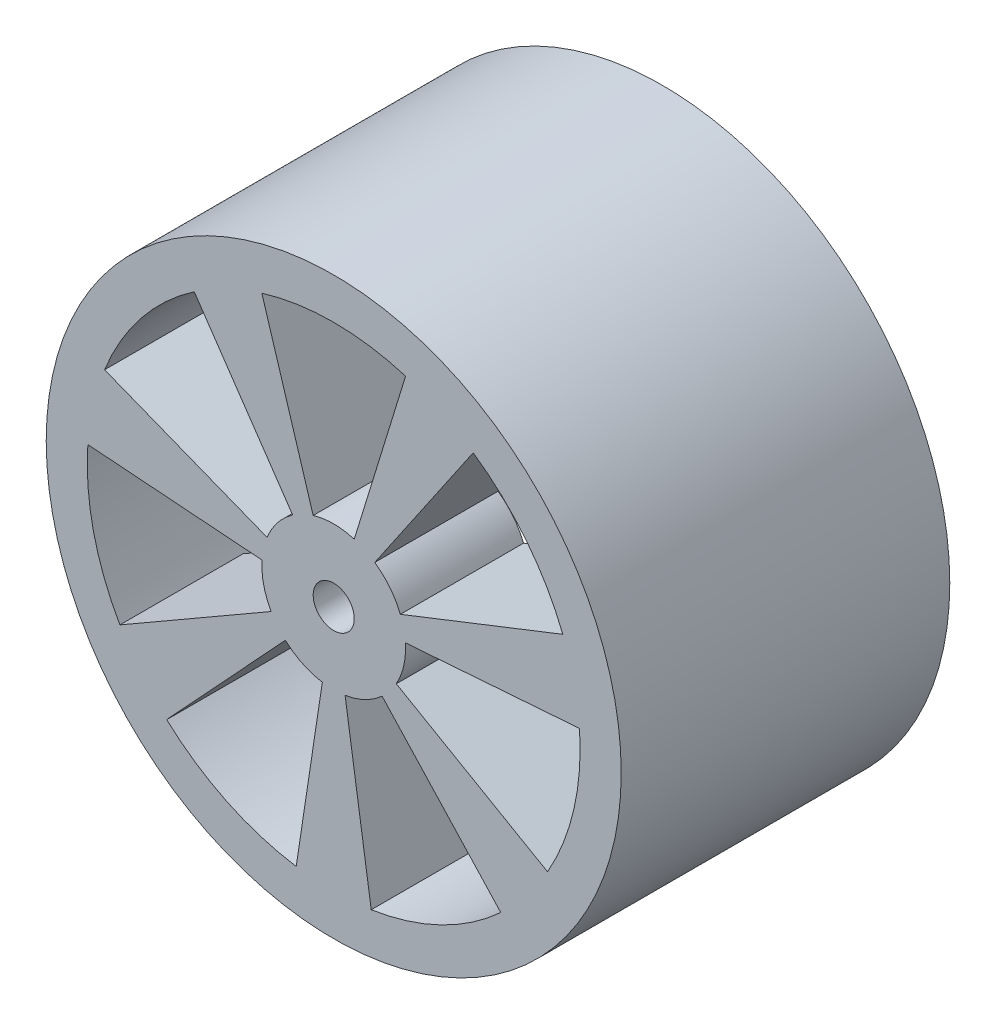
from build123d import *
from build123d.topology import SkipClean

# Parameters (mm, degrees)
SKETCH1_R           = 28
SKETCH1_R_2         = 2
BOSS_EXTRUDE1_DEPTH = 32
SKETCH2_R           = 24
CUT_EXTRUDE1_DEPTH  = 20
CUT_EXTRUDE2_DEPTH  = 4
CUT_EXTRUDE4_DEPTH  = 51.911688245


with BuildPart() as part:
    # Sketch1 → Boss-Extrude1 (new body)
    with BuildSketch(Plane.XY):
        Circle(SKETCH1_R)
        Circle(SKETCH1_R_2, mode=Mode.SUBTRACT)
    extrude(amount=BOSS_EXTRUDE1_DEPTH)

    # Sketch2 → Cut-Extrude1 (cut)
    with BuildSketch(Plane(origin=(0, 0, 0), x_dir=(-1, 0, 0), z_dir=(0, 0, -1))):
        Circle(SKETCH2_R)
    extrude(amount=-CUT_EXTRUDE1_DEPTH, mode=Mode.SUBTRACT)

    # Sketch3 → Cut-Extrude2 (cut)
    with BuildSketch(Plane(origin=(0, 0, 20), x_dir=(-1, 0, 0), z_dir=(0, 0, -1))):
        Polygon((6, 0), (3, 5.196152423), (-3, 5.196152423), (-6, 0), (-3, -5.196152423), (3, -5.196152423), align=None)
    extrude(amount=-CUT_EXTRUDE2_DEPTH, mode=Mode.SUBTRACT)

    # Sketch5 → Cut-Extrude4 (cut, through all)
    with SkipClean():  # the faces are left unmerged after this step: merging them gives an invalid solid
        with BuildSketch(Plane.XY.offset(32)):
            with BuildLine():
                Line((-7, 22.956480566), (-2, 6.708203932))
                ThreePointArc((-2, 6.708203932), (0, 7), (2, 6.708203932))
                Line((2, 6.708203932), (7, 22.956480566))
                ThreePointArc((7, 22.956480566), (0, 24), (-7, 22.956480566))
            make_face()
            with BuildLine():
                Line((13.583670621, 19.785951897), (3.997705422, 5.746159706))
                ThreePointArc((3.997705422, 5.746159706), (5.472820377, 4.364428613), (6.491664629, 2.618833776))
                Line((6.491664629, 2.618833776), (22.312527847, 8.840311143))
                ThreePointArc((22.312527847, 8.840311143), (18.763955579, 14.963755245), (13.583670621, 19.785951897))
            make_face()
            with BuildLine():
                Line((23.938560207, 1.716197889), (6.985057122, 0.45714002))
                ThreePointArc((6.985057122, 0.45714002), (6.824495385, -1.557646538), (6.094973386, -3.442571629))
                Line((6.094973386, -3.442571629), (20.823267132, -11.932792881))
                ThreePointArc((20.823267132, -11.932792881), (23.398269892, -5.340502415), (23.938560207, 1.716197889))
            make_face()
            with BuildLine():
                Line((16.2672257, -17.645888133), (4.712518341, -5.176115424))
                ThreePointArc((4.712518341, -5.176115424), (3.037186174, -6.306782075), (1.108642869, -6.911650381))
                Line((1.108642869, -6.911650381), (3.65366155, -23.720260481))
                ThreePointArc((3.65366155, -23.720260481), (10.413209739, -21.62325283), (16.2672257, -17.645888133))
            make_face()
            with BuildLine():
                Line((-3.65366155, -23.720260481), (-1.108642869, -6.911650381))
                ThreePointArc((-1.108642869, -6.911650381), (-3.037186174, -6.306782075), (-4.712518341, -5.176115424))
                Line((-4.712518341, -5.176115424), (-16.2672257, -17.645888133))
                ThreePointArc((-16.2672257, -17.645888133), (-10.413209739, -21.62325283), (-3.65366155, -23.720260481))
            make_face()
            with BuildLine():
                Line((-20.823267132, -11.932792881), (-6.094973386, -3.442571629))
                ThreePointArc((-6.094973386, -3.442571629), (-6.824495385, -1.557646538), (-6.985057122, 0.45714002))
                Line((-6.985057122, 0.45714002), (-23.938560207, 1.716197889))
                ThreePointArc((-23.938560207, 1.716197889), (-23.398269892, -5.340502415), (-20.823267132, -11.932792881))
            make_face()
            with BuildLine():
                Line((-22.312527847, 8.840311143), (-6.491664629, 2.618833776))
                ThreePointArc((-6.491664629, 2.618833776), (-5.472820377, 4.364428613), (-3.997705422, 5.746159706))
                Line((-3.997705422, 5.746159706), (-13.583670621, 19.785951897))
                ThreePointArc((-13.583670621, 19.785951897), (-18.763955579, 14.963755245), (-22.312527847, 8.840311143))
            make_face()
        extrude(amount=-CUT_EXTRUDE4_DEPTH, mode=Mode.SUBTRACT)


solid = part.part
